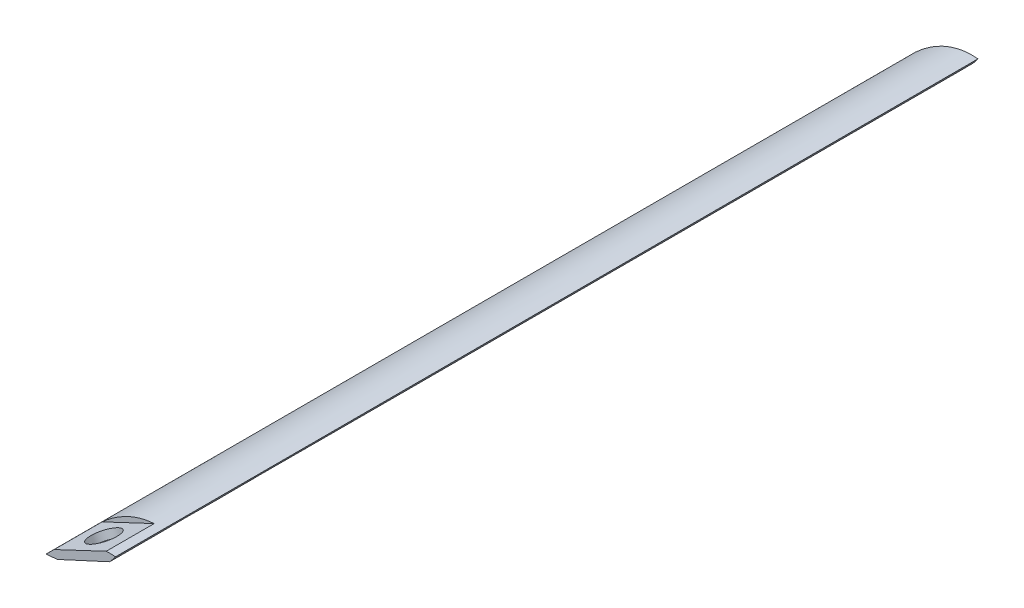
from build123d import *

# Parameters (mm, degrees)
EXTRUDE_1_DEPTH          = 90
CUT_EXTRUDE_1_DEPTH      = 91.355974503
CUT_EXTRUDE_1_DEPTH_BACK = 91.355974503
SKETCH_3_R               = 1.5
CUT_EXTRUDE_2_DEPTH      = 5


with BuildPart() as part:
    # 草图1 → 凸台-拉伸1 (new body)
    with BuildSketch(Plane.XY):
        with BuildLine():
            add(Edge.make_bspline(
                [(0, 0), (1.822213929, 1.963125521), (4.44688488, 3.658064856), (7.250299715, 3.38129473)],
                knots=[0, 0, 0, 0, 1, 1, 1, 1], degree=3))
            add(Edge.make_bspline(
                [(0, 0), (2.675125031, 0.134281362), (5.660541257, 1.055697067), (7.250299715, 3.38129473)],
                knots=[0, 0, 0, 0, 1, 1, 1, 1], degree=3))
        make_face()
    extrude(amount=EXTRUDE_1_DEPTH)

    # 草图3 → 切除-拉伸1 (cut, two sides: drawn at the far end of the back side and taken through both)
    with BuildSketch(Plane(origin=(0, 0, 0), x_dir=(-0.9062874643291001, -0.42266184119214045, 0), z_dir=(-0.42266184119214045, 0.9062874643291001, 0)).offset(-CUT_EXTRUDE_1_DEPTH_BACK)):
        with Locations((-4, 87.406495382)):
            Circle(SKETCH_3_R)
    extrude(amount=CUT_EXTRUDE_1_DEPTH + CUT_EXTRUDE_1_DEPTH_BACK, mode=Mode.SUBTRACT)

    # 草图4 → 切除-拉伸2 (cut)
    with BuildSketch(Plane.XY.offset(90)):
        Polygon((6.283899983, 3.400732971), (0.847709565, 0.837583253), (-0.20408354, 3.068333785), (5.375308773, 5.699002827), align=None)
    cut_extrude_2 = extrude(amount=-CUT_EXTRUDE_2_DEPTH, mode=Mode.SUBTRACT)

    # 镜向1: 切除-拉伸2 across plane
    add(cut_extrude_2.mirror(Plane(origin=(0, 0, 0), x_dir=(0, 0, 1), z_dir=(-0.42266184119214045, 0.9062874643291001, 0))), mode=Mode.SUBTRACT)


solid = part.part
